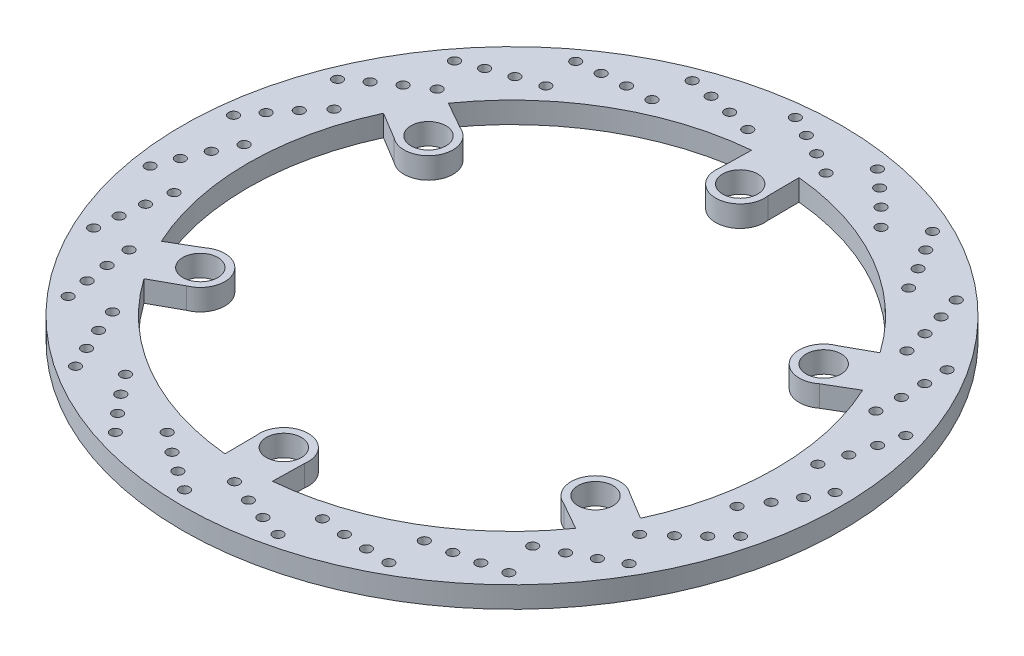
from build123d import *

# Parameters (mm, degrees)
SKETCH1_R           = 155.1
SKETCH1_R_2         = 8.225
SKETCH1_R_3         = 2.35
BOSS_EXTRUDE1_DEPTH = 10


with BuildPart() as part:
    # Sketch1 → Boss-Extrude1 (new body)
    with BuildSketch(Plane(origin=(0, 3.76, 0), x_dir=(1, 0, 0), z_dir=(0, 1, 0))):
        Circle(SKETCH1_R)
        with Locations((-92.997954647, -53.69239415)):
            Circle(SKETCH1_R_2, mode=Mode.SUBTRACT)
        with Locations((0, -107.3847883)):
            Circle(SKETCH1_R_2, mode=Mode.SUBTRACT)
        with Locations((92.997954647, -53.69239415)):
            Circle(SKETCH1_R_2, mode=Mode.SUBTRACT)
        with Locations((92.997954647, 53.69239415)):
            Circle(SKETCH1_R_2, mode=Mode.SUBTRACT)
        with Locations((0, 107.3847883)):
            Circle(SKETCH1_R_2, mode=Mode.SUBTRACT)
        with Locations((-92.997954647, 53.69239415)):
            Circle(SKETCH1_R_2, mode=Mode.SUBTRACT)
        with Locations((-14.108570086, 147.453516591)):
            Circle(SKETCH1_R_3, mode=Mode.SUBTRACT)
        with Locations((-4.23359466, 142.754245153)):
            Circle(SKETCH1_R_3, mode=Mode.SUBTRACT)
        with Locations((5.663589498, 137.721286806)):
            Circle(SKETCH1_R_3, mode=Mode.SUBTRACT)
        with Locations((15.772202274, 132.032177785)):
            Circle(SKETCH1_R_3, mode=Mode.SUBTRACT)
        with Locations((26.197096636, 145.79198686)):
            Circle(SKETCH1_R_3, mode=Mode.SUBTRACT)
        with Locations((34.438032925, 138.60274067)):
            Circle(SKETCH1_R_3, mode=Mode.SUBTRACT)
        with Locations((42.610326736, 131.086189742)):
            Circle(SKETCH1_R_3, mode=Mode.SUBTRACT)
        with Locations((50.809181485, 122.880777228)):
            Circle(SKETCH1_R_3, mode=Mode.SUBTRACT)
        with Locations((64.559844545, 133.317732418)):
            Circle(SKETCH1_R_3, mode=Mode.SUBTRACT)
        with Locations((70.555549152, 124.171704976)):
            Circle(SKETCH1_R_3, mode=Mode.SUBTRACT)
        with Locations((76.39685097, 114.729029664)):
            Circle(SKETCH1_R_3, mode=Mode.SUBTRACT)
        with Locations((82.077876141, 104.615871566)):
            Circle(SKETCH1_R_3, mode=Mode.SUBTRACT)
        with Locations((98.134484125, 110.955911651)):
            Circle(SKETCH1_R_3, mode=Mode.SUBTRACT)
        with Locations((101.440283069, 100.531421973)):
            Circle(SKETCH1_R_3, mode=Mode.SUBTRACT)
        with Locations((104.517370259, 89.862942306)):
            Circle(SKETCH1_R_3, mode=Mode.SUBTRACT)
        with Locations((107.259230205, 78.592085295)):
            Circle(SKETCH1_R_3, mode=Mode.SUBTRACT)
        with Locations((124.430937954, 80.364998506)):
            Circle(SKETCH1_R_3, mode=Mode.SUBTRACT)
        with Locations((124.801655248, 69.435183302)):
            Circle(SKETCH1_R_3, mode=Mode.SUBTRACT)
        with Locations((124.886314331, 58.332131612)):
            Circle(SKETCH1_R_3, mode=Mode.SUBTRACT)
        with Locations((124.485657843, 46.739483593)):
            Circle(SKETCH1_R_3, mode=Mode.SUBTRACT)
        with Locations((141.498918347, 43.813781067)):
            Circle(SKETCH1_R_3, mode=Mode.SUBTRACT)
        with Locations((138.907059588, 33.189254731)):
            Circle(SKETCH1_R_3, mode=Mode.SUBTRACT)
        with Locations((135.993011786, 22.475093569)):
            Circle(SKETCH1_R_3, mode=Mode.SUBTRACT)
        with Locations((132.479553723, 11.420428212)):
            Circle(SKETCH1_R_3, mode=Mode.SUBTRACT)
        with Locations((148.072571282, 4.013095921)):
            Circle(SKETCH1_R_3, mode=Mode.SUBTRACT)
        with Locations((142.710362775, -5.518169033)):
            Circle(SKETCH1_R_3, mode=Mode.SUBTRACT)
        with Locations((137.013729684, -15.048819347)):
            Circle(SKETCH1_R_3, mode=Mode.SUBTRACT)
        with Locations((130.648047157, -24.745628084)):
            Circle(SKETCH1_R_3, mode=Mode.SUBTRACT)
        with Locations((143.664358991, -36.08522219)):
            Circle(SKETCH1_R_3, mode=Mode.SUBTRACT)
        with Locations((135.929491212, -43.816335444)):
            Circle(SKETCH1_R_3, mode=Mode.SUBTRACT)
        with Locations((127.872766047, -51.456630177)):
            Circle(SKETCH1_R_3, mode=Mode.SUBTRACT)
        with Locations((119.126972609, -59.07641435)):
            Circle(SKETCH1_R_3, mode=Mode.SUBTRACT)
        with Locations((128.601218415, -73.507264451)):
            Circle(SKETCH1_R_3, mode=Mode.SUBTRACT)
        with Locations((119.067351122, -78.864844702)):
            Circle(SKETCH1_R_3, mode=Mode.SUBTRACT)
        with Locations((109.248064331, -84.048138144)):
            Circle(SKETCH1_R_3, mode=Mode.SUBTRACT)
        with Locations((98.770795471, -89.025773219)):
            Circle(SKETCH1_R_3, mode=Mode.SUBTRACT)
        with Locations((104.00031378, -105.477609181)):
            Circle(SKETCH1_R_3, mode=Mode.SUBTRACT)
        with Locations((93.374530296, -108.06430921)):
            Circle(SKETCH1_R_3, mode=Mode.SUBTRACT)
        with Locations((82.520933461, -110.4061802)):
            Circle(SKETCH1_R_3, mode=Mode.SUBTRACT)
        with Locations((71.08924028, -112.372497755)):
            Circle(SKETCH1_R_3, mode=Mode.SUBTRACT)
        with Locations((71.686181642, -129.625162165)):
            Circle(SKETCH1_R_3, mode=Mode.SUBTRACT)
        with Locations((60.756547717, -129.249138266)):
            Circle(SKETCH1_R_3, mode=Mode.SUBTRACT)
        with Locations((49.673602464, -128.575900945)):
            Circle(SKETCH1_R_3, mode=Mode.SUBTRACT)
        with Locations((38.135321349, -127.385068202)):
            Circle(SKETCH1_R_3, mode=Mode.SUBTRACT)
        with Locations((34.055413355, -144.159009868)):
            Circle(SKETCH1_R_3, mode=Mode.SUBTRACT)
        with Locations((23.632529938, -140.848150011)):
            Circle(SKETCH1_R_3, mode=Mode.SUBTRACT)
        with Locations((13.142207614, -137.209735313)):
            Circle(SKETCH1_R_3, mode=Mode.SUBTRACT)
        with Locations((2.353080091, -132.950070889)):
            Circle(SKETCH1_R_3, mode=Mode.SUBTRACT)
        with Locations((-6.101089149, -148.001243292)):
            Circle(SKETCH1_R_3, mode=Mode.SUBTRACT)
        with Locations((-15.244204476, -142.001098808)):
            Circle(SKETCH1_R_3, mode=Mode.SUBTRACT)
        with Locations((-24.363884654, -135.667351305)):
            Circle(SKETCH1_R_3, mode=Mode.SUBTRACT)
        with Locations((-33.603678353, -128.654775024)):
            Circle(SKETCH1_R_3, mode=Mode.SUBTRACT)
        with Locations((-45.80510178, -140.866901562)):
            Circle(SKETCH1_R_3, mode=Mode.SUBTRACT)
        with Locations((-52.990345981, -132.622475719)):
            Circle(SKETCH1_R_3, mode=Mode.SUBTRACT)
        with Locations((-60.063019054, -124.063140488)):
            Circle(SKETCH1_R_3, mode=Mode.SUBTRACT)
        with Locations((-67.0682057, -114.817743052)):
            Circle(SKETCH1_R_3, mode=Mode.SUBTRACT)
        with Locations((-82.111959557, -123.285106167)):
            Circle(SKETCH1_R_3, mode=Mode.SUBTRACT)
        with Locations((-86.806435939, -113.407850312)):
            Circle(SKETCH1_R_3, mode=Mode.SUBTRACT)
        with Locations((-91.3075541, -103.257734092)):
            Circle(SKETCH1_R_3, mode=Mode.SUBTRACT)
        with Locations((-95.558591047, -92.465204333)):
            Circle(SKETCH1_R_3, mode=Mode.SUBTRACT)
        with Locations((-112.328948931, -96.559818438)):
            Circle(SKETCH1_R_3, mode=Mode.SUBTRACT)
        with Locations((-114.184489657, -85.782283455)):
            Circle(SKETCH1_R_3, mode=Mode.SUBTRACT)
        with Locations((-115.780225564, -74.794173931)):
            Circle(SKETCH1_R_3, mode=Mode.SUBTRACT)
        with Locations((-116.961832847, -63.25494441)):
            Circle(SKETCH1_R_3, mode=Mode.SUBTRACT)
        with Locations((-134.215014034, -62.673130708)):
            Circle(SKETCH1_R_3, mode=Mode.SUBTRACT)
        with Locations((-133.094002136, -51.794637061)):
            Circle(SKETCH1_R_3, mode=Mode.SUBTRACT)
        with Locations((-131.666007356, -40.78347205)):
            Circle(SKETCH1_R_3, mode=Mode.SUBTRACT)
        with Locations((-129.69055057, -29.353354632)):
            Circle(SKETCH1_R_3, mode=Mode.SUBTRACT)
        with Locations((-146.146965538, -24.138263584)):
            Circle(SKETCH1_R_3, mode=Mode.SUBTRACT)
        with Locations((-142.132541342, -13.965619381)):
            Circle(SKETCH1_R_3, mode=Mode.SUBTRACT)
        with Locations((-137.786723715, -3.748046619)):
            Circle(SKETCH1_R_3, mode=Mode.SUBTRACT)
        with Locations((-132.800713452, 6.725239177)):
            Circle(SKETCH1_R_3, mode=Mode.SUBTRACT)
        with Locations((-147.239865186, 16.186828125)):
            Circle(SKETCH1_R_3, mode=Mode.SUBTRACT)
        with Locations((-140.629760169, 24.8991644)):
            Circle(SKETCH1_R_3, mode=Mode.SUBTRACT)
        with Locations((-133.688429108, 33.565354283)):
            Circle(SKETCH1_R_3, mode=Mode.SUBTRACT)
        with Locations((-126.06165494, 42.305052761)):
            Circle(SKETCH1_R_3, mode=Mode.SUBTRACT)
        with Locations((-137.412657611, 55.311416842)):
            Circle(SKETCH1_R_3, mode=Mode.SUBTRACT)
        with Locations((-128.697113022, 61.917291063)):
            Circle(SKETCH1_R_3, mode=Mode.SUBTRACT)
        with Locations((-119.675075299, 68.38936641)):
            Circle(SKETCH1_R_3, mode=Mode.SUBTRACT)
        with Locations((-109.973180174, 74.747294116)):
            Circle(SKETCH1_R_3, mode=Mode.SUBTRACT)
        with Locations((-117.394181842, 90.333810804)):
            Circle(SKETCH1_R_3, mode=Mode.SUBTRACT)
        with Locations((-107.219589753, 94.343295501)):
            Circle(SKETCH1_R_3, mode=Mode.SUBTRACT)
        with Locations((-96.785968631, 98.14125209)):
            Circle(SKETCH1_R_3, mode=Mode.SUBTRACT)
        with Locations((-85.728497729, 101.645870611)):
            Circle(SKETCH1_R_3, mode=Mode.SUBTRACT)
        with Locations((-88.669116649, 118.656559269)):
            Circle(SKETCH1_R_3, mode=Mode.SUBTRACT)
        with Locations((-77.790080009, 119.772289304)):
            Circle(SKETCH1_R_3, mode=Mode.SUBTRACT)
        with Locations((-66.718689436, 120.614450069)):
            Circle(SKETCH1_R_3, mode=Mode.SUBTRACT)
        with Locations((-55.12572479, 121.005837883)):
            Circle(SKETCH1_R_3, mode=Mode.SUBTRACT)
        with Locations((-53.367868707, 138.179093551)):
            Circle(SKETCH1_R_3, mode=Mode.SUBTRACT)
        with Locations((-42.591235897, 136.31832033)):
            Circle(SKETCH1_R_3, mode=Mode.SUBTRACT)
        with Locations((-31.703190264, 134.142226062)):
            Circle(SKETCH1_R_3, mode=Mode.SUBTRACT)
        with Locations((-20.434529026, 131.391355723)):
            Circle(SKETCH1_R_3, mode=Mode.SUBTRACT)
        with BuildLine():
            Line((-100.11647971, -44.66041757), (-112.853215519, -52.157784257))
            ThreePointArc((-112.853215519, -52.157784257), (-124.323272454, 0.08147429), (-112.784756217, 52.305654348))
            Line((-112.784756217, 52.305654348), (-100.11647971, 44.66041757))
            ThreePointArc((-100.11647971, 44.66041757), (-83.038662504, 47.94239415), (-88.735296015, 64.373205981))
            Line((-88.735296015, 64.373205981), (-101.596573932, 71.65485941))
            ThreePointArc((-101.596573932, 71.65485941), (-62.091077422, 107.707849372), (-11.094352681, 123.827291218))
            Line((-11.094352681, 123.827291218), (-11.381183696, 109.033623552))
            ThreePointArc((-11.381183696, 109.033623552), (0, 95.8847883), (11.381183696, 109.033623552))
            Line((11.381183696, 109.033623552), (11.256641588, 123.812643667))
            ThreePointArc((11.256641588, 123.812643667), (62.232195032, 107.626375082), (101.690403536, 71.521636869))
            Line((101.690403536, 71.521636869), (88.735296015, 64.373205981))
            ThreePointArc((88.735296015, 64.373205981), (83.038662504, 47.94239415), (100.11647971, 44.66041757))
            Line((100.11647971, 44.66041757), (112.853215519, 52.157784258))
            ThreePointArc((112.853215519, 52.157784258), (124.323272454, -0.08147429), (112.784756217, -52.305654348))
            Line((112.784756217, -52.305654348), (100.11647971, -44.66041757))
            ThreePointArc((100.11647971, -44.66041757), (83.038662504, -47.94239415), (88.735296015, -64.373205981))
            Line((88.735296015, -64.373205981), (101.596573932, -71.65485941))
            ThreePointArc((101.596573932, -71.65485941), (62.091077422, -107.707849372), (11.094352681, -123.827291218))
            Line((11.094352681, -123.827291218), (11.381183696, -109.033623552))
            ThreePointArc((11.381183696, -109.033623552), (0, -95.8847883), (-11.381183696, -109.033623552))
            Line((-11.381183696, -109.033623552), (-11.256641588, -123.812643667))
            ThreePointArc((-11.256641588, -123.812643667), (-62.232195032, -107.626375082), (-101.690403536, -71.521636869))
            Line((-101.690403536, -71.521636869), (-88.735296015, -64.373205981))
            ThreePointArc((-88.735296015, -64.373205981), (-83.038662504, -47.94239415), (-100.11647971, -44.66041757))
        make_face(mode=Mode.SUBTRACT)
    extrude(amount=-BOSS_EXTRUDE1_DEPTH)


solid = part.part
